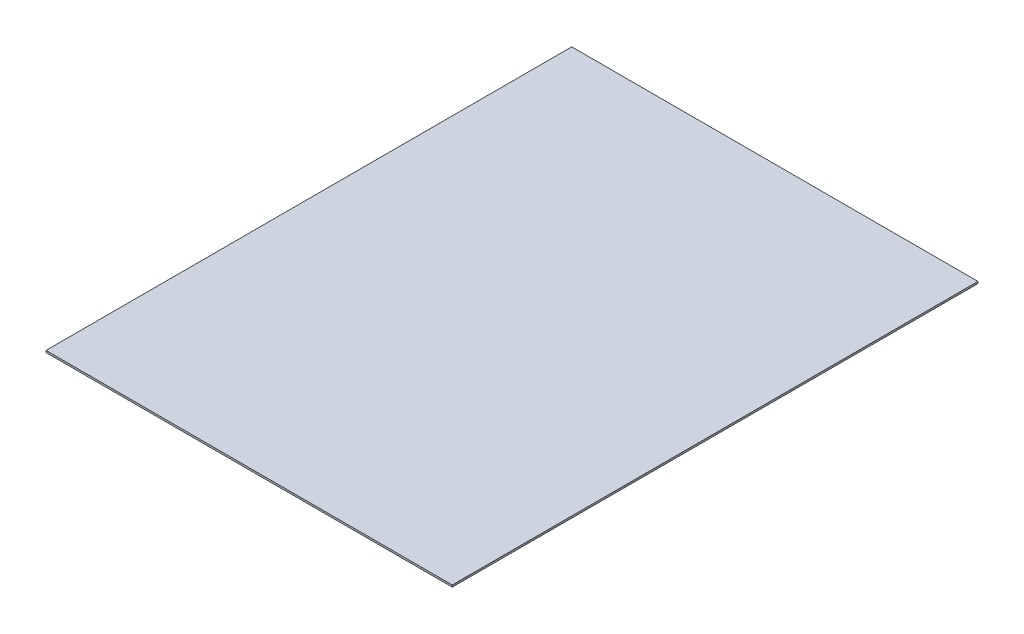
from build123d import *

# Parameters (mm, degrees)
SKETCH1_W           = 215.9
SKETCH1_H           = 279.4
BOSS_EXTRUDE1_DEPTH = 1


with BuildPart() as part:
    # Sketch1 → Boss-Extrude1 (new body)
    with BuildSketch(Plane(origin=(0, 0, 0), x_dir=(1, 0, 0), z_dir=(0, 1, 0))):
        Rectangle(SKETCH1_W, SKETCH1_H)
    extrude(amount=BOSS_EXTRUDE1_DEPTH)


solid = part.part
